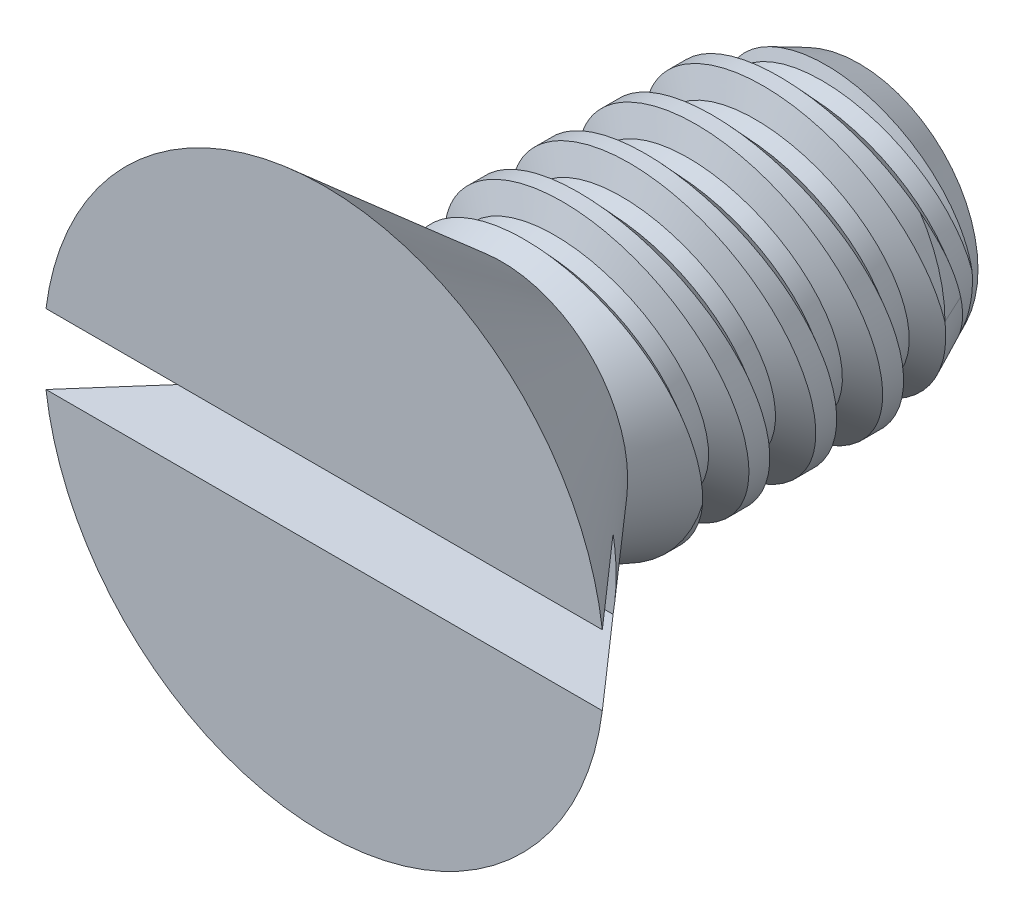
from build123d import *

# Parameters (mm, degrees)
SKETCH1_R          = 3.3274
EXTRUDE3_DEPTH     = 2.1082
SKETCH4_W          = 4.2418
SKETCH4_H          = 1.7526
LPATTERN2_COUNT    = 5
LPATTERN2_PITCH    = 0.79375
SKETCH15_W         = 6.6548
SKETCH15_H         = 0.83185
CUT_EXTRUDE5_DEPTH = 1.0541


with BuildPart() as part:
    # Sketch1 → Extrude3 (new body)
    with BuildSketch(Plane.XY):
        Circle(SKETCH1_R)
    extrude(amount=EXTRUDE3_DEPTH)

    # Sketch11 → Cut-Revolve3 (revolve, cut)
    with BuildSketch(Plane(origin=(0, 0, 0), x_dir=(0, 0, -1), z_dir=(1, 0, 0))):
        Polygon((0, 1.494769699), (-2.1082, 3.3274), (0, 3.3274), align=None)
    revolve(axis=Axis((0, 0, -0.441444004), (0, 0, 1)), mode=Mode.SUBTRACT)

    # Sketch4 → Revolve1 (revolve)
    with BuildSketch(Plane(origin=(0, 0, 0), x_dir=(0, 0, -1), z_dir=(1, 0, 0))):
        with Locations((2.1209, 0.8763)):
            Rectangle(SKETCH4_W, SKETCH4_H)
    revolve(axis=Axis((0, 0, -4.2418), (0, 0, -1)))

    # Sketch5 → Cut-Revolve1 (revolve, cut)
    with BuildSketch(Plane(origin=(0, 0, 0), x_dir=(0, 0, -1), z_dir=(1, 0, 0))):
        Polygon((0.096768654, 1.774513192), (0.433577192, 1.410275607), (0.6271145, 1.454101991), (0.774149232, 1.927905533), align=None)
    cut_revolve1 = revolve(axis=Axis((0, -0.193538035, 0), (0, 0.220857364, -0.975306119)), mode=Mode.SUBTRACT)

    # Sketch13 → Cut-Revolve4 (revolve, cut)
    with BuildSketch(Plane(origin=(0, 0, 0), x_dir=(0, 0, -1), z_dir=(1, 0, 0))):
        Polygon((4.2418, 1.410275607), (3.507682971, 1.7526), (4.2418, 1.7526), align=None)
    revolve(axis=Axis((0, 0, 0), (0, 0, -1)), mode=Mode.SUBTRACT)

    # Sketch16 → Cut-Revolve5 (revolve, cut)
    with BuildSketch(Plane(origin=(0, 0, 0), x_dir=(0, 0, -1), z_dir=(1, 0, 0))):
        Polygon((0, 1.494769699), (0.708382929, 1.7526), (0, 1.7526), align=None)
    revolve(axis=Axis((0, 0, 0), (0, 0, -1)), mode=Mode.SUBTRACT)

    # LPattern2: Cut-Revolve1 ×5
    with Locations(*[(0, 0, -i * LPATTERN2_PITCH) for i in range(1, LPATTERN2_COUNT)]):
        add(cut_revolve1, mode=Mode.SUBTRACT)

    # Sketch15 → Cut-Extrude5 (cut)
    with BuildSketch(Plane.XY.offset(2.1082)):
        Rectangle(SKETCH15_W, SKETCH15_H)
    extrude(amount=-CUT_EXTRUDE5_DEPTH, mode=Mode.SUBTRACT)


solid = part.part
